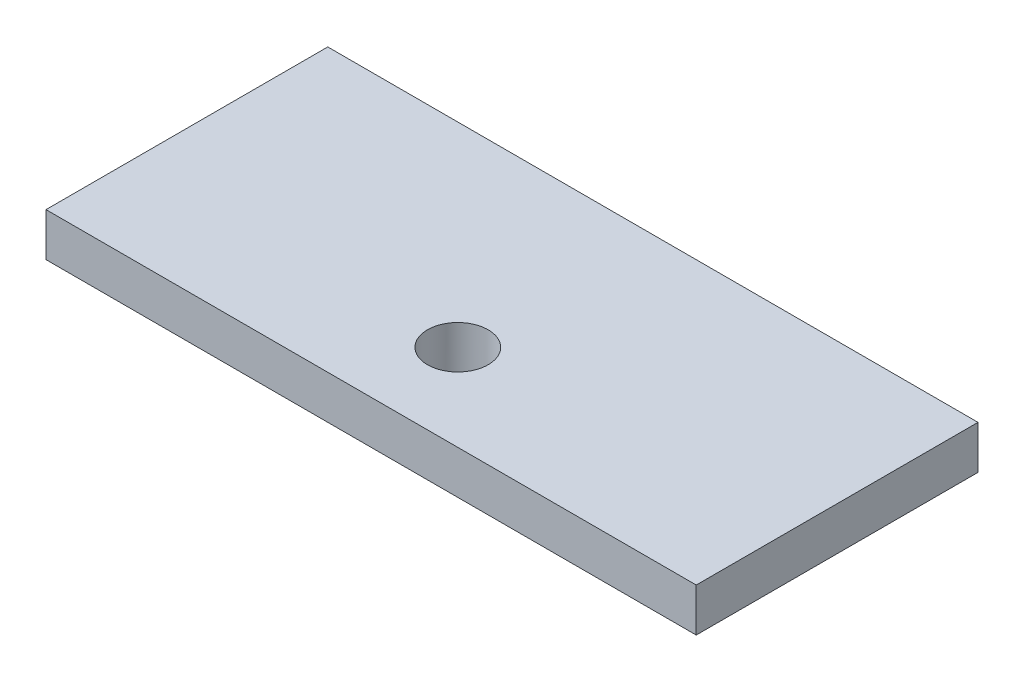
from build123d import *

# Parameters (mm, degrees)
SKETCH1_W               = 150
SKETCH1_H               = 65
BOSS_EXTRUDE1_DEPTH     = 10
SKETCH2_R               = 7
CUT_EXTRUDE2_DEPTH      = 11
CUT_EXTRUDE2_DEPTH_BACK = 1


with BuildPart() as part:
    # Sketch1 → Boss-Extrude1 (new body)
    with BuildSketch(Plane(origin=(0, 0, 0), x_dir=(1, 0, 0), z_dir=(0, 1, 0))):
        Rectangle(SKETCH1_W, SKETCH1_H)
    extrude(amount=BOSS_EXTRUDE1_DEPTH)

    # Sketch2 → Cut-Extrude2 (cut, two sides)
    with BuildSketch(Plane(origin=(0, 0, 0), x_dir=(1, 0, 0), z_dir=(0, 1, 0))) as cut_extrude2_sk:
        with Locations((0, -12.5)):
            Circle(SKETCH2_R)
    extrude(amount=CUT_EXTRUDE2_DEPTH, mode=Mode.SUBTRACT)
    extrude(cut_extrude2_sk.sketch, amount=-CUT_EXTRUDE2_DEPTH_BACK, mode=Mode.SUBTRACT)


solid = part.part
